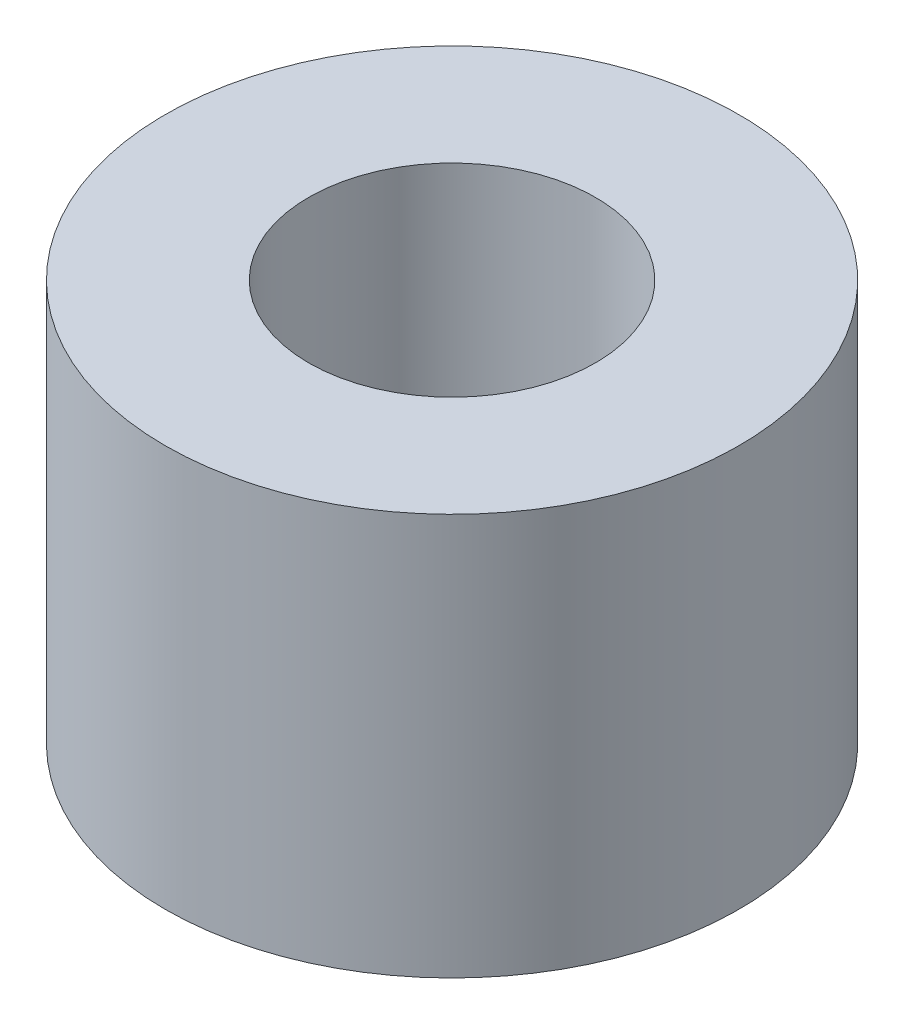
from build123d import *

# Parameters (mm, degrees)
SKETCH_1_R      = 5
SKETCH_1_R_2    = 2.5
EXTRUDE_1_DEPTH = 7


with BuildPart() as part:
    # Эскиз1 → Бобышка-Вытянуть1 (new body)
    with BuildSketch(Plane(origin=(0, 0, 0), x_dir=(1, 0, 0), z_dir=(0, 1, 0))):
        Circle(SKETCH_1_R)
        Circle(SKETCH_1_R_2, mode=Mode.SUBTRACT)
    extrude(amount=EXTRUDE_1_DEPTH)


solid = part.part
